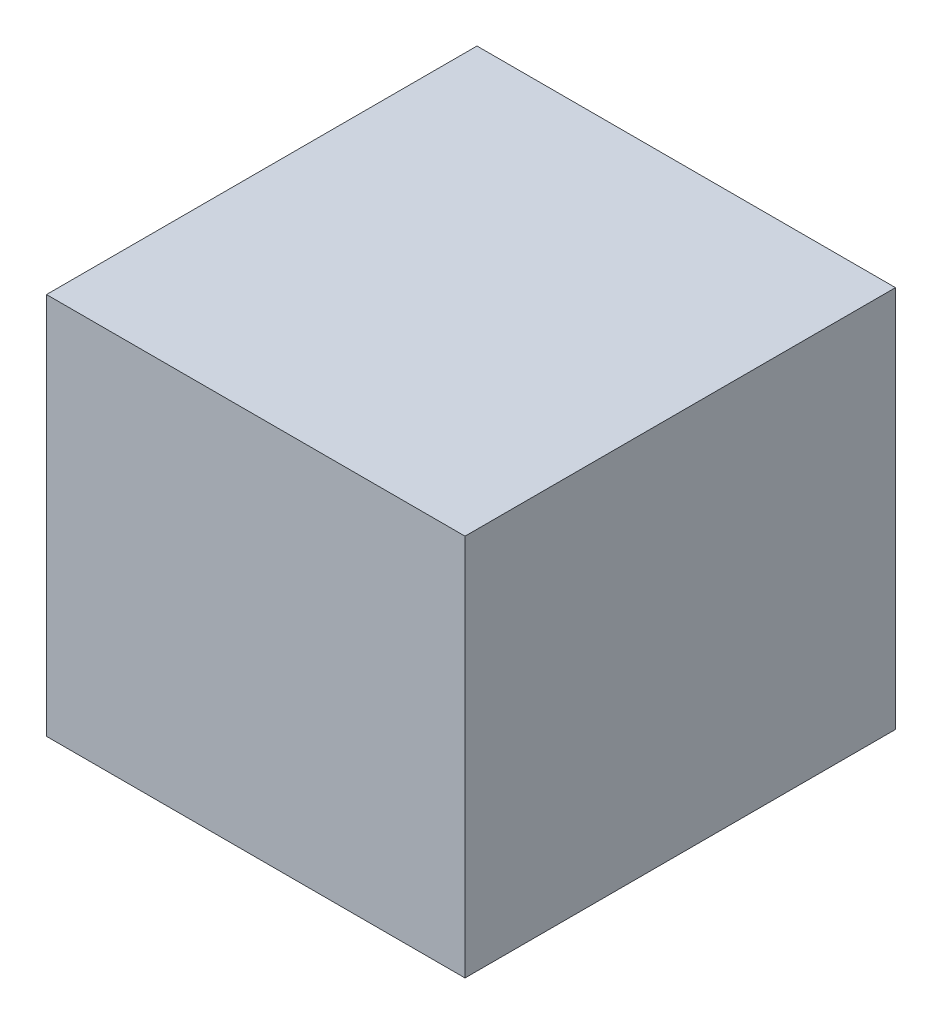
from build123d import *

# Parameters (mm, degrees)
SCHIZZO1_W                   = 35
SCHIZZO1_H                   = 27
ESTRUSIONE_ESTRUSIONE1_DEPTH = 36
SCHIZZO3_R                   = 5
TAGLIO_ESTRUSIONE1_DEPTH     = 28
SCHIZZO4_R                   = 11
TAGLIO_ESTRUSIONE2_DEPTH     = 3.5
SCHIZZO7_W                   = 35
SCHIZZO7_H                   = 36
ESTRUSIONE_ESTRUSIONE3_DEPTH = 5


with BuildPart() as part:
    # Schizzo1 → Estrusione-Estrusione1 (new body)
    with BuildSketch(Plane.XY):
        Rectangle(SCHIZZO1_W, SCHIZZO1_H)
    extrude(amount=ESTRUSIONE_ESTRUSIONE1_DEPTH)

    # Schizzo3 → Taglio-Estrusione1 (cut, through all)
    with BuildSketch(Plane(origin=(0, 13.5, 0), x_dir=(1, 0, 0), z_dir=(0, 1, 0))):
        with Locations((0, -18)):
            Circle(SCHIZZO3_R)
    extrude(amount=-TAGLIO_ESTRUSIONE1_DEPTH, mode=Mode.SUBTRACT)

    # Schizzo4 → Taglio-Estrusione2 (cut)
    with BuildSketch(Plane.XZ.offset(13.5)):
        with Locations((0, 18)):
            Circle(SCHIZZO4_R)
    extrude(amount=-TAGLIO_ESTRUSIONE2_DEPTH, mode=Mode.SUBTRACT)

    # Schizzo7 → Estrusione-Estrusione3 (add)
    with BuildSketch(Plane(origin=(0, 13.5, 0), x_dir=(1, 0, 0), z_dir=(0, 1, 0))):
        with Locations((0, -18)):
            Rectangle(SCHIZZO7_W, SCHIZZO7_H)
    extrude(amount=ESTRUSIONE_ESTRUSIONE3_DEPTH)


solid = part.part
